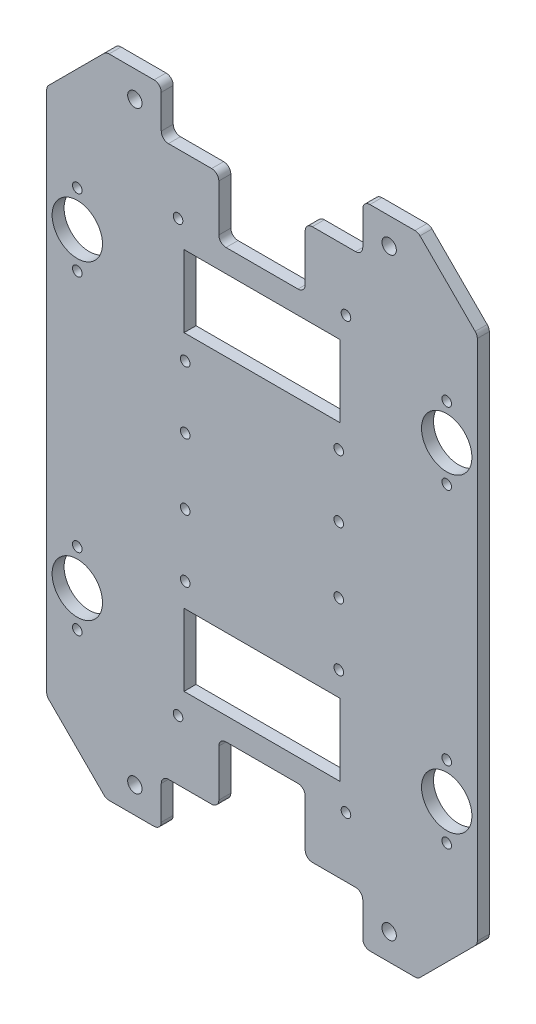
from build123d import *

# Parameters (mm, degrees)
BASE_DEPTH                = 5
ESQUISSE3_R               = 2
ESQUISSE3_W               = 65
ESQUISSE3_H               = 30
ENL_V_MAT_EXTRU_1_DEPTH   = 6
CONG_1_R                  = 3
PER_AGE_POUR_BILLES_REACH = 7
ESQUISSE6_R               = 2
ESQUISSE6_R_2             = 10.5
PER_AGE_POUR_PROFIL_REACH = 7
ESQUISSE8_R               = 3
ESQUISSE10_R              = 2
ENL_V_MAT_EXTRU_3_DEPTH   = 6


with BuildPart() as part:
    # Esquisse1 → Base (new body)
    with BuildSketch(Plane.XY):
        Polygon((0, 0), (-130, 0), (-154.748737342, 24.748737342), (-154.748737342, 244.748737342), (-130, 269.497474683), (0, 269.497474683), (24.748737342, 244.748737342), (24.748737342, 24.748737342), align=None)
    extrude(amount=BASE_DEPTH)

    # Esquisse3 → Enlèv. mat.-Extru.1 (cut, through all)
    with BuildSketch(Plane(origin=(0, 0, 0), x_dir=(-1, 0, 0), z_dir=(0, 0, -1))):
        with Locations((30, 45)):
            Circle(ESQUISSE3_R)
        with Locations((100, 45)):
            Circle(ESQUISSE3_R)
        with Locations((100, 224.497474683)):
            Circle(ESQUISSE3_R)
        with Locations((30, 224.497474683)):
            Circle(ESQUISSE3_R)
        Polygon((107, 0), (107, 20), (83, 20), (83, 45.5), (47, 45.5), (47, 20), (23, 20), (23, 0), align=None)
        Polygon((23, 269.497474683), (107, 269.497474683), (107, 249.497474683), (83, 249.497474683), (83, 223.997474683), (47, 223.997474683), (47, 249.497474683), (23, 249.497474683), align=None)
        with Locations((65, 199.497474683)):
            Rectangle(ESQUISSE3_W, ESQUISSE3_H)
        with Locations((65, 70)):
            Rectangle(ESQUISSE3_W, ESQUISSE3_H)
    extrude(amount=-ENL_V_MAT_EXTRU_1_DEPTH, mode=Mode.SUBTRACT)

    # Congé1
    cong_1_edges = [part.edges().sort_by_distance(p)[0] for p in [
        (0, 0, 2.5),
        (-130, 0, 2.5),
        (-154.748737342, 24.748737342, 2.5),
        (-154.748737342, 244.748737342, 2.5),
        (-130, 269.497474683, 2.5),
        (0, 269.497474683, 2.5),
        (24.748737342, 244.748737342, 2.5),
        (24.748737342, 24.748737342, 2.5),
        (-23, 249.497474683, 2.5),
        (-23, 269.497474683, 2.5),
        (-107, 269.497474683, 2.5),
        (-107, 249.497474683, 2.5),
        (-83, 249.497474683, 2.5),
        (-83, 223.997474683, 2.5),
        (-47, 223.997474683, 2.5),
        (-47, 249.497474683, 2.5),
        (-107, 0, 2.5),
        (-23, 0, 2.5),
        (-23, 20, 2.5),
        (-47, 20, 2.5),
        (-47, 45.5, 2.5),
        (-83, 45.5, 2.5),
        (-83, 20, 2.5),
        (-107, 20, 2.5),
    ]]
    fillet(cong_1_edges, radius=CONG_1_R)

    # Esquisse6 → Perçage pour billes (cut, up to next)
    with BuildSketch(Plane.XY.offset(5), mode=Mode.PRIVATE) as per_age_pour_billes_sk1:
        with Locations((-142, 55)):
            Circle(ESQUISSE6_R)
    per_age_pour_billes_tool1 = extrude(per_age_pour_billes_sk1.sketch, amount=-PER_AGE_POUR_BILLES_REACH, mode=Mode.PRIVATE) & part.part
    add(per_age_pour_billes_tool1.solids().sort_by_distance((-142, 55, 5))[0], mode=Mode.SUBTRACT)
    # Esquisse6 → Perçage pour billes (cut, up to next)
    with BuildSketch(Plane.XY.offset(5), mode=Mode.PRIVATE) as per_age_pour_billes_sk2:
        with Locations((-142, 85)):
            Circle(ESQUISSE6_R)
    per_age_pour_billes_tool2 = extrude(per_age_pour_billes_sk2.sketch, amount=-PER_AGE_POUR_BILLES_REACH, mode=Mode.PRIVATE) & part.part
    add(per_age_pour_billes_tool2.solids().sort_by_distance((-142, 85, 5))[0], mode=Mode.SUBTRACT)
    # Esquisse6 → Perçage pour billes (cut, up to next)
    with BuildSketch(Plane.XY.offset(5), mode=Mode.PRIVATE) as per_age_pour_billes_sk3:
        with Locations((-142, 70)):
            Circle(ESQUISSE6_R_2)
    per_age_pour_billes_tool3 = extrude(per_age_pour_billes_sk3.sketch, amount=-PER_AGE_POUR_BILLES_REACH, mode=Mode.PRIVATE) & part.part
    add(per_age_pour_billes_tool3.solids().sort_by_distance((-142, 70, 5))[0], mode=Mode.SUBTRACT)
    # Esquisse6 → Perçage pour billes (cut, up to next)
    with BuildSketch(Plane.XY.offset(5), mode=Mode.PRIVATE) as per_age_pour_billes_sk4:
        with Locations((-142, 214.497474683)):
            Circle(ESQUISSE6_R)
    per_age_pour_billes_tool4 = extrude(per_age_pour_billes_sk4.sketch, amount=-PER_AGE_POUR_BILLES_REACH, mode=Mode.PRIVATE) & part.part
    add(per_age_pour_billes_tool4.solids().sort_by_distance((-142, 214.497475, 5))[0], mode=Mode.SUBTRACT)
    # Esquisse6 → Perçage pour billes (cut, up to next)
    with BuildSketch(Plane.XY.offset(5), mode=Mode.PRIVATE) as per_age_pour_billes_sk5:
        with Locations((-142, 184.497474683)):
            Circle(ESQUISSE6_R)
    per_age_pour_billes_tool5 = extrude(per_age_pour_billes_sk5.sketch, amount=-PER_AGE_POUR_BILLES_REACH, mode=Mode.PRIVATE) & part.part
    add(per_age_pour_billes_tool5.solids().sort_by_distance((-142, 184.497475, 5))[0], mode=Mode.SUBTRACT)
    # Esquisse6 → Perçage pour billes (cut, up to next)
    with BuildSketch(Plane.XY.offset(5), mode=Mode.PRIVATE) as per_age_pour_billes_sk6:
        with Locations((-142, 199.497474683)):
            Circle(ESQUISSE6_R_2)
    per_age_pour_billes_tool6 = extrude(per_age_pour_billes_sk6.sketch, amount=-PER_AGE_POUR_BILLES_REACH, mode=Mode.PRIVATE) & part.part
    add(per_age_pour_billes_tool6.solids().sort_by_distance((-142, 199.497475, 5))[0], mode=Mode.SUBTRACT)
    # Esquisse6 → Perçage pour billes (cut, up to next)
    with BuildSketch(Plane.XY.offset(5), mode=Mode.PRIVATE) as per_age_pour_billes_sk7:
        with Locations((12, 55)):
            Circle(ESQUISSE6_R)
    per_age_pour_billes_tool7 = extrude(per_age_pour_billes_sk7.sketch, amount=-PER_AGE_POUR_BILLES_REACH, mode=Mode.PRIVATE) & part.part
    add(per_age_pour_billes_tool7.solids().sort_by_distance((12, 55, 5))[0], mode=Mode.SUBTRACT)
    # Esquisse6 → Perçage pour billes (cut, up to next)
    with BuildSketch(Plane.XY.offset(5), mode=Mode.PRIVATE) as per_age_pour_billes_sk8:
        with Locations((12, 184.497474683)):
            Circle(ESQUISSE6_R)
    per_age_pour_billes_tool8 = extrude(per_age_pour_billes_sk8.sketch, amount=-PER_AGE_POUR_BILLES_REACH, mode=Mode.PRIVATE) & part.part
    add(per_age_pour_billes_tool8.solids().sort_by_distance((12, 184.497475, 5))[0], mode=Mode.SUBTRACT)
    # Esquisse6 → Perçage pour billes (cut, up to next)
    with BuildSketch(Plane.XY.offset(5), mode=Mode.PRIVATE) as per_age_pour_billes_sk9:
        with Locations((12, 214.497474683)):
            Circle(ESQUISSE6_R)
    per_age_pour_billes_tool9 = extrude(per_age_pour_billes_sk9.sketch, amount=-PER_AGE_POUR_BILLES_REACH, mode=Mode.PRIVATE) & part.part
    add(per_age_pour_billes_tool9.solids().sort_by_distance((12, 214.497475, 5))[0], mode=Mode.SUBTRACT)
    # Esquisse6 → Perçage pour billes (cut, up to next)
    with BuildSketch(Plane.XY.offset(5), mode=Mode.PRIVATE) as per_age_pour_billes_sk10:
        with Locations((12, 85)):
            Circle(ESQUISSE6_R)
    per_age_pour_billes_tool10 = extrude(per_age_pour_billes_sk10.sketch, amount=-PER_AGE_POUR_BILLES_REACH, mode=Mode.PRIVATE) & part.part
    add(per_age_pour_billes_tool10.solids().sort_by_distance((12, 85, 5))[0], mode=Mode.SUBTRACT)
    # Esquisse6 → Perçage pour billes (cut, up to next)
    with BuildSketch(Plane.XY.offset(5), mode=Mode.PRIVATE) as per_age_pour_billes_sk11:
        with Locations((12, 70)):
            Circle(ESQUISSE6_R_2)
    per_age_pour_billes_tool11 = extrude(per_age_pour_billes_sk11.sketch, amount=-PER_AGE_POUR_BILLES_REACH, mode=Mode.PRIVATE) & part.part
    add(per_age_pour_billes_tool11.solids().sort_by_distance((12, 70, 5))[0], mode=Mode.SUBTRACT)
    # Esquisse6 → Perçage pour billes (cut, up to next)
    with BuildSketch(Plane.XY.offset(5), mode=Mode.PRIVATE) as per_age_pour_billes_sk12:
        with Locations((12, 199.497474683)):
            Circle(ESQUISSE6_R_2)
    per_age_pour_billes_tool12 = extrude(per_age_pour_billes_sk12.sketch, amount=-PER_AGE_POUR_BILLES_REACH, mode=Mode.PRIVATE) & part.part
    add(per_age_pour_billes_tool12.solids().sort_by_distance((12, 199.497475, 5))[0], mode=Mode.SUBTRACT)

    # Esquisse8 → Perçage pour profilé (cut, up to next)
    with BuildSketch(Plane.XY.offset(5), mode=Mode.PRIVATE) as per_age_pour_profil_sk1:
        with Locations((-118, 11)):
            Circle(ESQUISSE8_R)
    per_age_pour_profil_tool1 = extrude(per_age_pour_profil_sk1.sketch, amount=-PER_AGE_POUR_PROFIL_REACH, mode=Mode.PRIVATE) & part.part
    add(per_age_pour_profil_tool1.solids().sort_by_distance((-118, 11, 5))[0], mode=Mode.SUBTRACT)
    # Esquisse8 → Perçage pour profilé (cut, up to next)
    with BuildSketch(Plane.XY.offset(5), mode=Mode.PRIVATE) as per_age_pour_profil_sk2:
        with Locations((-118, 258.497474683)):
            Circle(ESQUISSE8_R)
    per_age_pour_profil_tool2 = extrude(per_age_pour_profil_sk2.sketch, amount=-PER_AGE_POUR_PROFIL_REACH, mode=Mode.PRIVATE) & part.part
    add(per_age_pour_profil_tool2.solids().sort_by_distance((-118, 258.497475, 5))[0], mode=Mode.SUBTRACT)
    # Esquisse8 → Perçage pour profilé (cut, up to next)
    with BuildSketch(Plane.XY.offset(5), mode=Mode.PRIVATE) as per_age_pour_profil_sk3:
        with Locations((-12, 258.497474683)):
            Circle(ESQUISSE8_R)
    per_age_pour_profil_tool3 = extrude(per_age_pour_profil_sk3.sketch, amount=-PER_AGE_POUR_PROFIL_REACH, mode=Mode.PRIVATE) & part.part
    add(per_age_pour_profil_tool3.solids().sort_by_distance((-12, 258.497475, 5))[0], mode=Mode.SUBTRACT)
    # Esquisse8 → Perçage pour profilé (cut, up to next)
    with BuildSketch(Plane.XY.offset(5), mode=Mode.PRIVATE) as per_age_pour_profil_sk4:
        with Locations((-12, 11)):
            Circle(ESQUISSE8_R)
    per_age_pour_profil_tool4 = extrude(per_age_pour_profil_sk4.sketch, amount=-PER_AGE_POUR_PROFIL_REACH, mode=Mode.PRIVATE) & part.part
    add(per_age_pour_profil_tool4.solids().sort_by_distance((-12, 11, 5))[0], mode=Mode.SUBTRACT)

    # Esquisse10 → Enlèv. mat.-Extru.3 (cut, through all)
    with BuildSketch(Plane.XY.offset(5)):
        with Locations((-97, 174.497474683)):
            Circle(ESQUISSE10_R)
        with Locations((-97, 148.497474683)):
            Circle(ESQUISSE10_R)
        with Locations((-33, 148.497474683)):
            Circle(ESQUISSE10_R)
        with Locations((-33, 174.497474683)):
            Circle(ESQUISSE10_R)
        with Locations((-33, 121)):
            Circle(ESQUISSE10_R)
        with Locations((-33, 95)):
            Circle(ESQUISSE10_R)
        with Locations((-97, 121)):
            Circle(ESQUISSE10_R)
        with Locations((-97, 95)):
            Circle(ESQUISSE10_R)
    extrude(amount=-ENL_V_MAT_EXTRU_3_DEPTH, mode=Mode.SUBTRACT)


solid = part.part
